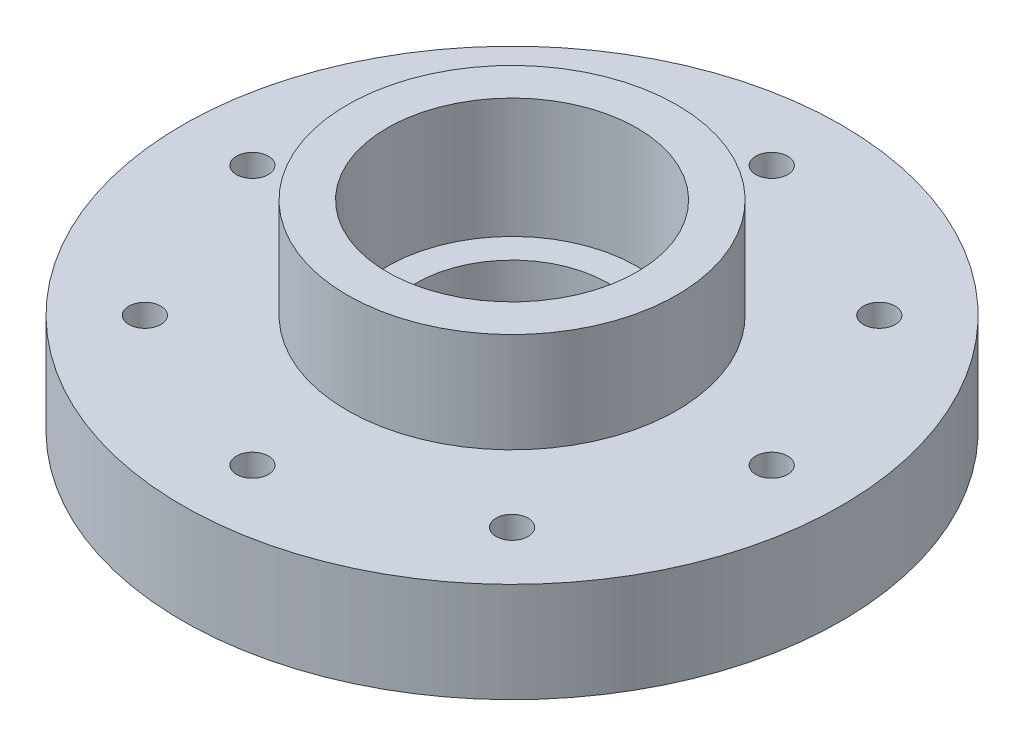
from build123d import *

# Parameters (mm, degrees)
SKETCH3_R          = 4
CUT_EXTRUDE2_DEPTH = 51


with BuildPart() as part:
    # Sketch2 → Revolve1 (revolve)
    with BuildSketch(Plane.XY):
        Polygon((82.5, 0), (56, 0), (56, 6), (24, 6), (24, 20), (31.256462168, 20), (31.256462168, 50), (41.256462168, 50), (41.256462168, 25), (82.5, 25), align=None)
    revolve(axis=Axis((0, 0, 0), (0, 1, 0)))

    # Sketch3 → Cut-Extrude2 (cut, through all)
    with BuildSketch(Plane.XZ):
        with Locations((65, 0)):
            Circle(SKETCH3_R)
        with Locations((45.961940777, -45.961940777)):
            Circle(SKETCH3_R)
        with Locations((0, -65)):
            Circle(SKETCH3_R)
        with Locations((-45.961940777, -45.961940777)):
            Circle(SKETCH3_R)
        with Locations((-65, 0)):
            Circle(SKETCH3_R)
        with Locations((-45.961940777, 45.961940777)):
            Circle(SKETCH3_R)
        with Locations((0, 65)):
            Circle(SKETCH3_R)
        with Locations((45.961940777, 45.961940777)):
            Circle(SKETCH3_R)
    extrude(amount=-CUT_EXTRUDE2_DEPTH, mode=Mode.SUBTRACT)


solid = part.part
